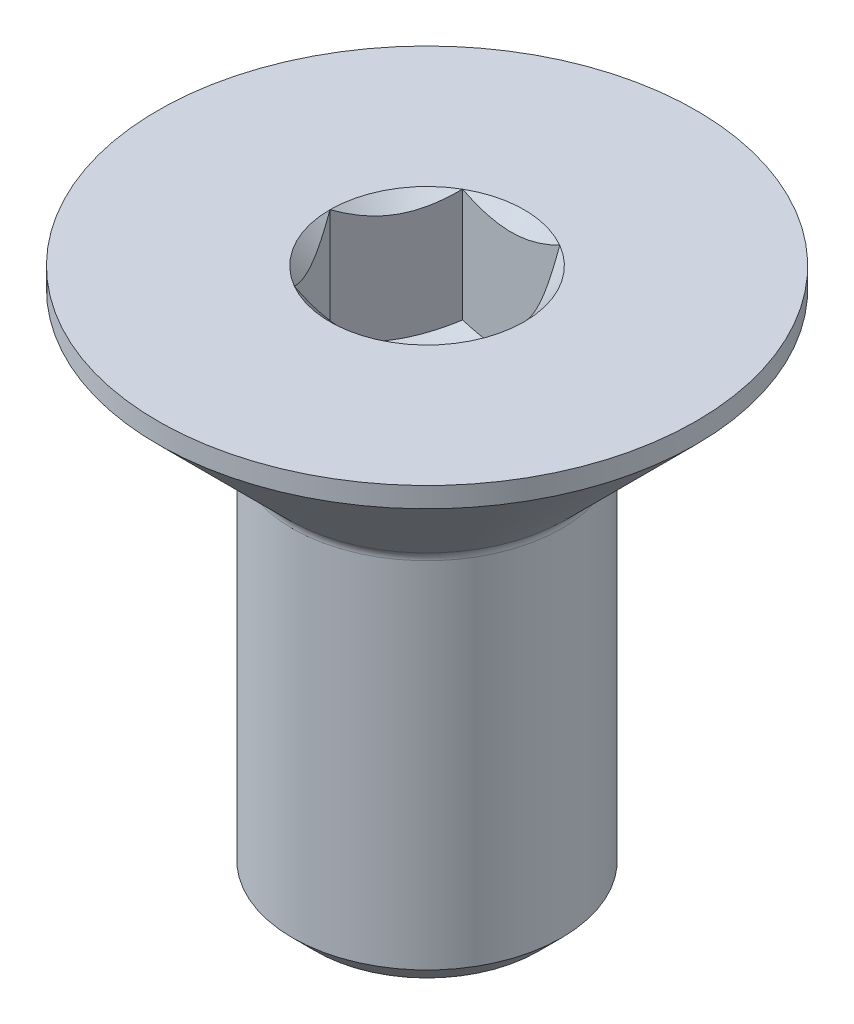
from build123d import *

# Parameters (mm, degrees)
CORTE_EXTRUS_O1_REACH = 11.798


with BuildPart() as part:
    # Esboço1 → Revolução1 (revolve)
    with BuildSketch(Plane.XY):
        with BuildLine():
            Line((0, -2.551075774), (1.25, -1.8))
            Line((1.25, -1.8), (1.25, 0))
            Line((1.25, 0), (4, 0))
            Line((4, 0), (4, -0.3))
            Line((4, -0.3), (2.058578644, -2.241421356))
            ThreePointArc((2.058578644, -2.241421356), (2.015224094, -2.306306026), (2, -2.382842712))
            Line((2, -2.382842712), (2, -7.65))
            Line((2, -7.65), (1.65, -8))
            Line((1.65, -8), (0, -8))
            Line((0, -8), (0, -2.551075774))
        make_face()
    revolve(axis=Axis((0, -1000, 0), (0, 1, 0)))

    # Corte-extrusão1: up to this cone (the profile starts inside it)
    corte_extrus_o1_end = Plane(origin=(0, 0, 0), z_dir=(0, 1, 0)).offset(-2.551074774) * Cone(1.664e-06, 31.779048647, 19.094777842, align=(Align.CENTER, Align.CENTER, Align.MIN), mode=Mode.PRIVATE)
    # Esboço2 → Corte-extrusão1 (cut, up to the surface)
    with BuildSketch(Plane(origin=(0, 0, 0), x_dir=(1, 0, 0), z_dir=(0, 1, 0)), mode=Mode.PRIVATE) as corte_extrus_o1_sk1:
        Polygon((-1.443375673, 0), (-0.721687836, -1.25), (0.721687836, -1.25), (1.443375673, 0), (0.721687836, 1.25), (-0.721687836, 1.25), align=None)
    corte_extrus_o1_tool1 = extrude(corte_extrus_o1_sk1.sketch, amount=-CORTE_EXTRUS_O1_REACH, mode=Mode.PRIVATE) & corte_extrus_o1_end
    add(corte_extrus_o1_tool1.solids().sort_by_distance((0, 0, 0))[0], mode=Mode.SUBTRACT)

    # Esboço3 → Corte-Revolução1 (revolve, cut)
    with BuildSketch(Plane.XY, mode=Mode.PRIVATE) as corte_revolu_o1_sk:
        Polygon((1.443375673, 0), (0, -1.443375673), (0, 0), align=None)
    revolve(corte_revolu_o1_sk.sketch.rotate(Axis((0, -1000, 0), (0, 1, 0)), 180), axis=Axis((0, -1000, 0), (0, 1, 0)), mode=Mode.SUBTRACT)


solid = part.part
